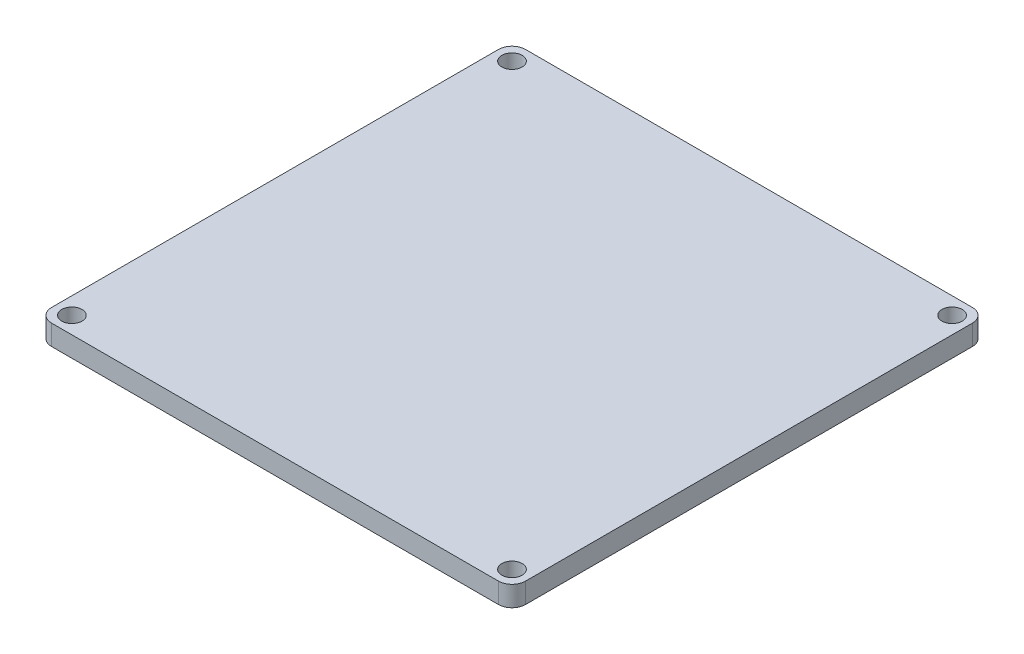
from build123d import *

# Parameters (mm, degrees)
SKETCH1_W           = 70
SKETCH1_H           = 70
SKETCH1_R           = 1.5
BOSS_EXTRUDE1_DEPTH = 3
FILLET1_R           = 2


with BuildPart() as part:
    # Sketch1 → Boss-Extrude1 (new body)
    with BuildSketch(Plane(origin=(0, 0, 0), x_dir=(1, 0, 0), z_dir=(0, 1, 0))):
        Rectangle(SKETCH1_W, SKETCH1_H)
        with Locations((-32.5, 32.5)):
            Circle(SKETCH1_R, mode=Mode.SUBTRACT)
        with Locations((32.5, 32.5)):
            Circle(SKETCH1_R, mode=Mode.SUBTRACT)
        with Locations((32.5, -32.5)):
            Circle(SKETCH1_R, mode=Mode.SUBTRACT)
        with Locations((-32.5, -32.5)):
            Circle(SKETCH1_R, mode=Mode.SUBTRACT)
    extrude(amount=BOSS_EXTRUDE1_DEPTH)

    # Fillet1
    fillet1_edges = [part.edges().sort_by_distance(p)[0] for p in [
        (35, 1.5, 35),
        (-35, 1.5, 35),
        (-35, 1.5, -35),
        (35, 1.5, -35),
    ]]
    fillet(fillet1_edges, radius=FILLET1_R)


solid = part.part
